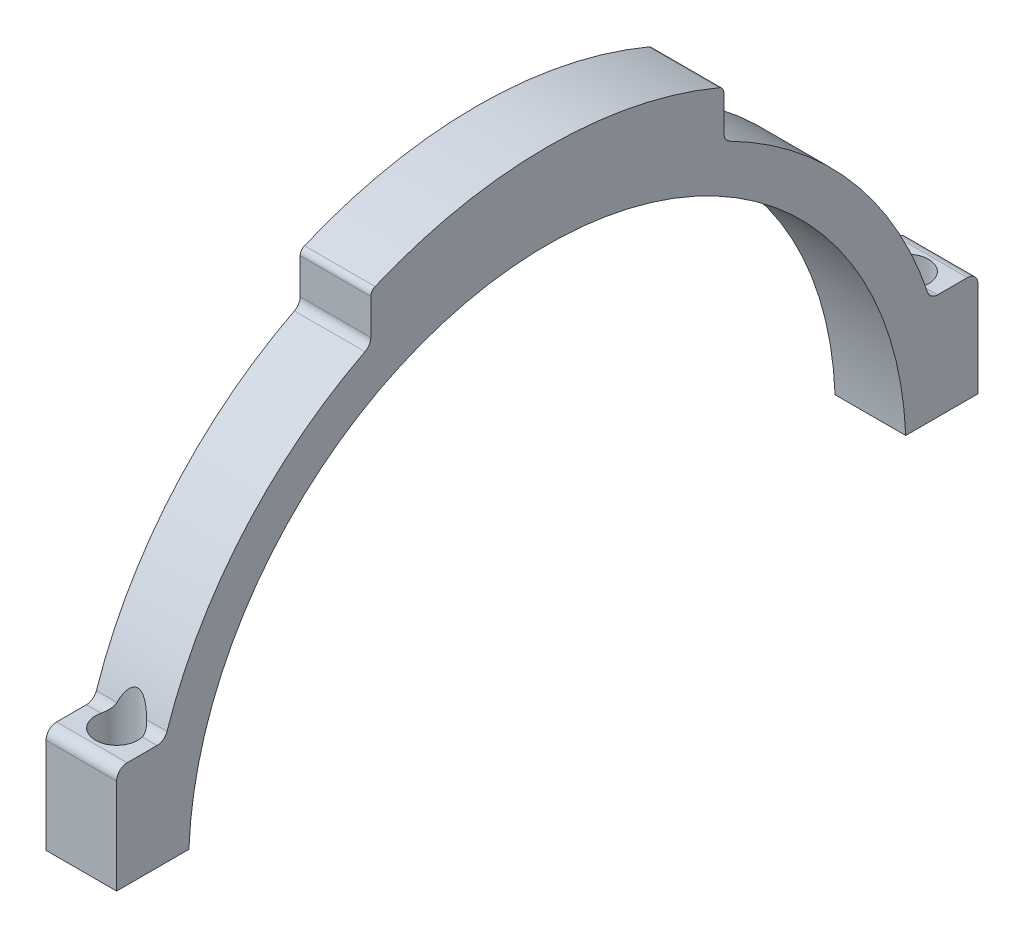
from build123d import *

# Parameters (mm, degrees)
BOSS_EXTRUDE1_DEPTH           = 10
M4_CLEARANCE_HOLE1_AT_2_COUNT = 2
M4_CLEARANCE_HOLE1_AT_2_PITCH = 112
SKETCH6_R                     = 3
CUT_EXTRUDE1_DEPTH            = 8
CUT_EXTRUDE1_DEPTH_BACK       = 6
FILLET1_R                     = 1


with BuildPart() as part:
    # Sketch1 → Boss-Extrude1 (new body)
    with BuildSketch(Plane(origin=(0, 0, 0), x_dir=(0, 0, -1), z_dir=(1, 0, 0))):
        with BuildLine():
            ThreePointArc((25, 57.609374237), (12.766583292, 61.488652214), (0, 62.8))
            ThreePointArc((0, 62.8), (-12.766583292, 61.488652214), (-25, 57.609374237))
            Line((-25, 57.609374237), (-25, 51.929182547))
            ThreePointArc((-25, 51.929182547), (-25.220795702, 51.145833095), (-25.818181818, 50.593097233))
            ThreePointArc((-25.818181818, 50.593097233), (-43.035646203, 37.069841595), (-53.859344034, 18.039153533))
            ThreePointArc((-53.859344034, 18.039153533), (-54.405495004, 17.298046479), (-55.281685866, 17.01553963))
            Line((-55.281685866, 17.01553963), (-59.5, 17.01553963))
            ThreePointArc((-59.5, 17.01553963), (-60.560660172, 16.576199802), (-61, 15.51553963))
            Line((-61, 15.51553963), (-61, 2.01553963))
            Line((-61, 2.01553963), (-50.76, 2.01553963))
            ThreePointArc((-50.76, 2.01553963), (0, 50.8), (50.76, 2.01553963))
            Line((50.76, 2.01553963), (61, 2.01553963))
            Line((61, 2.01553963), (61, 15.51553963))
            ThreePointArc((61, 15.51553963), (60.560660172, 16.576199802), (59.5, 17.01553963))
            Line((59.5, 17.01553963), (55.281685866, 17.01553963))
            ThreePointArc((55.281685866, 17.01553963), (54.405495004, 17.298046479), (53.859344034, 18.039153533))
            ThreePointArc((53.859344034, 18.039153533), (43.035646203, 37.069841595), (25.818181818, 50.593097233))
            ThreePointArc((25.818181818, 50.593097233), (25.220795702, 51.145833095), (25, 51.929182547))
            Line((25, 51.929182547), (25, 57.609374237))
        make_face()
    extrude(amount=BOSS_EXTRUDE1_DEPTH)

    # Sketch4 → M4 Clearance Hole1 (revolve, cut)
    with BuildSketch(Plane(origin=(5, 17.01553963, -56), x_dir=(0, 0, 1), z_dir=(1, 0, 0))):
        Polygon((0, 0), (0, 16.351936393), (2.25, 15), (2.25, 0), align=None)
    m4_clearance_hole1 = revolve(axis=Axis((5, 23.36553963, -56), (0, -1, 0)), mode=Mode.SUBTRACT)

    # M4 Clearance Hole1 at 2: M4 Clearance Hole1 ×2
    with Locations(*[(0, 0, i * M4_CLEARANCE_HOLE1_AT_2_PITCH) for i in range(1, M4_CLEARANCE_HOLE1_AT_2_COUNT)]):
        add(m4_clearance_hole1, mode=Mode.SUBTRACT)

    # Sketch6 → Cut-Extrude1 (cut, two sides)
    with BuildSketch(Plane(origin=(0, 17.01553963, 0), x_dir=(1, 0, 0), z_dir=(0, 1, 0))) as cut_extrude1_sk:
        with Locations((5, 56)):
            Circle(SKETCH6_R)
        with Locations((5, -56)):
            Circle(SKETCH6_R)
    extrude(amount=CUT_EXTRUDE1_DEPTH, mode=Mode.SUBTRACT)
    extrude(cut_extrude1_sk.sketch, amount=-CUT_EXTRUDE1_DEPTH_BACK, mode=Mode.SUBTRACT)

    # Fillet1
    fillet1_edges = [part.edges().sort_by_distance(p)[0] for p in [
        (5, 57.609374237, -25),
        (5, 57.609374237, 25),
    ]]
    fillet(fillet1_edges, radius=FILLET1_R)


solid = part.part
